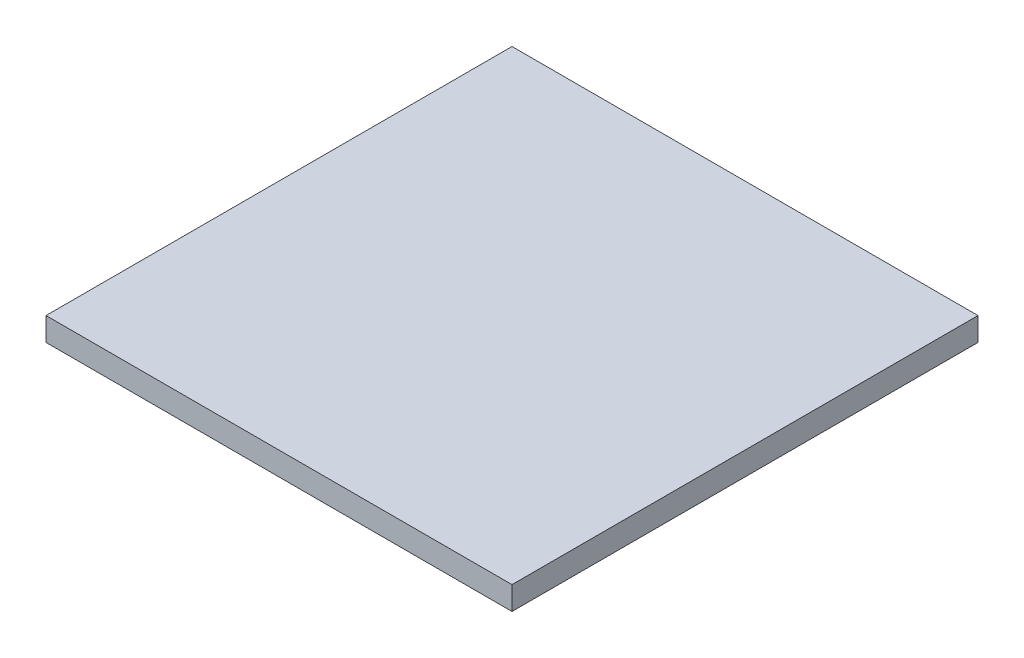
from build123d import *

# Parameters (mm, degrees)
SKETCH1_W           = 100
SKETCH1_H           = 100
BOSS_EXTRUDE1_DEPTH = 5


with BuildPart() as part:
    # Sketch1 → Boss-Extrude1 (new body)
    with BuildSketch(Plane(origin=(0, 0, 0), x_dir=(1, 0, 0), z_dir=(0, 1, 0))):
        with Locations((50, 50)):
            Rectangle(SKETCH1_W, SKETCH1_H)
    extrude(amount=BOSS_EXTRUDE1_DEPTH)


solid = part.part
